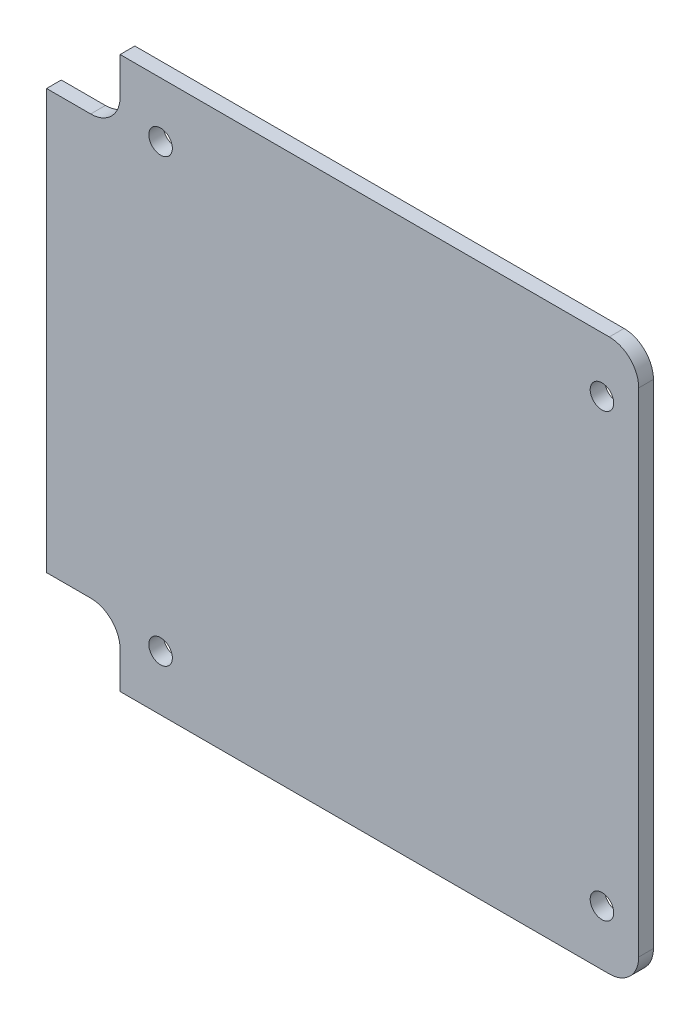
from build123d import *

# Parameters (mm, degrees)
SKETCH_1_R      = 1.6
EXTRUDE_1_DEPTH = 2
FILLET_1_R      = 4


with BuildPart() as part:
    # ｽｹｯﾁ1 → ﾎﾞｽ - 押し出し1 (new body)
    with BuildSketch(Plane.XY):
        Polygon((40.25, 37.5), (-30.25, 37.5), (-30.25, 28.5), (-40.25, 28.5), (-40.25, -28.5), (-30.25, -28.5), (-30.25, -37.5), (40.25, -37.5), align=None)
        with Locations((-24.75, -30)):
            Circle(SKETCH_1_R, mode=Mode.SUBTRACT)
        with Locations((35.25, -30)):
            Circle(SKETCH_1_R, mode=Mode.SUBTRACT)
        with Locations((-24.75, 30)):
            Circle(SKETCH_1_R, mode=Mode.SUBTRACT)
        with Locations((35.25, 30)):
            Circle(SKETCH_1_R, mode=Mode.SUBTRACT)
    extrude(amount=EXTRUDE_1_DEPTH)

    # ﾌｨﾚｯﾄ1
    fillet_1_edges = [part.edges().sort_by_distance(p)[0] for p in [
        (-30.25, -28.5, 1),
        (-30.25, 28.5, 1),
        (40.25, 37.5, 1),
        (40.25, -37.5, 1),
    ]]
    fillet(fillet_1_edges, radius=FILLET_1_R)


solid = part.part
